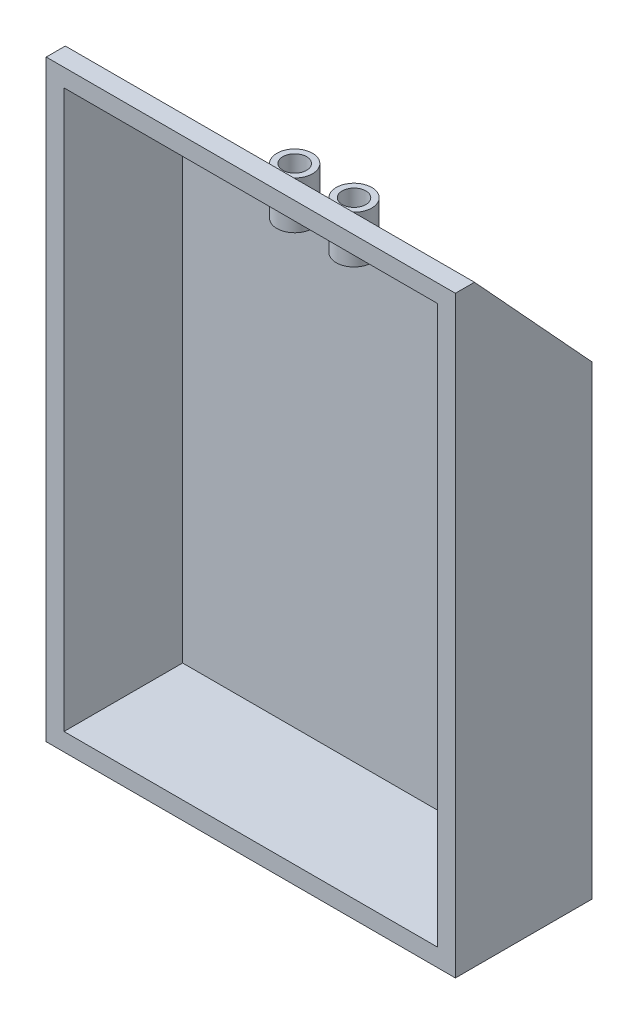
from build123d import *

# Parameters (mm, degrees)
IZIM1_W                     = 69
IZIM1_H                     = 100
Y_KSEKLIK_EKSTR_ZYON1_DEPTH = 3
IZIM2_W                     = 69
IZIM2_H                     = 100
IZIM2_W_2                   = 63
IZIM2_H_2                   = 94
Y_KSEKLIK_EKSTR_ZYON2_DEPTH = 20
KES_EKSTR_ZYON1_DEPTH       = 70
Y_KSEKLIK_EKSTR_ZYON3_DEPTH = 69
IZIM5_R                     = 3
KES_EKSTR_ZYON2_DEPTH       = 20
Y_KSEKLIK_EKSTR_ZYON4_START = -15
IZIM6_R                     = 3
IZIM6_R_2                   = 2
Y_KSEKLIK_EKSTR_ZYON4_DEPTH = 8


with BuildPart() as part:
    # Çizim1 → Yükseklik-Ekstrüzyon1 (new body)
    with BuildSketch(Plane.XY):
        Rectangle(IZIM1_W, IZIM1_H)
    extrude(amount=Y_KSEKLIK_EKSTR_ZYON1_DEPTH)

    # Çizim2 → Yükseklik-Ekstrüzyon2 (add)
    with BuildSketch(Plane.XY.offset(3)):
        Rectangle(IZIM2_W, IZIM2_H)
        Rectangle(IZIM2_W_2, IZIM2_H_2, mode=Mode.SUBTRACT)
    extrude(amount=Y_KSEKLIK_EKSTR_ZYON2_DEPTH)

    # Çizim3 → Kes-Ekstrüzyon1 (cut, through all)
    with BuildSketch(Plane(origin=(34.5, 0, 0), x_dir=(0, 0, -1), z_dir=(1, 0, 0))):
        Polygon((-23, 50), (0, 25), (0, 50), align=None)
    extrude(amount=-KES_EKSTR_ZYON1_DEPTH, mode=Mode.SUBTRACT)

    # Çizim4 → Yükseklik-Ekstrüzyon3 (add, through all)
    with BuildSketch(Plane(origin=(34.5, 0, 0), x_dir=(0, 0, -1), z_dir=(1, 0, 0))):
        Polygon((-23, 50), (-19.78, 50), (0, 28.5), (0, 25), align=None)
    extrude(amount=-Y_KSEKLIK_EKSTR_ZYON3_DEPTH)

    # Çizim5 → Kes-Ekstrüzyon2 (cut)
    with BuildSketch(Plane(origin=(0, 50, 0), x_dir=(1, 0, 0), z_dir=(0, 1, 0))):
        with Locations((-5, -10.594226135)):
            Circle(IZIM5_R)
        with Locations((5, -10.594226135)):
            Circle(IZIM5_R)
    extrude(amount=-KES_EKSTR_ZYON2_DEPTH, mode=Mode.SUBTRACT)

    # Çizim6 → Yükseklik-Ekstrüzyon4 (add)
    with BuildSketch(Plane(origin=(0, 50, 0), x_dir=(1, 0, 0), z_dir=(0, 1, 0)).offset(Y_KSEKLIK_EKSTR_ZYON4_START)):
        with Locations((-5, -10.594226135)):
            Circle(IZIM6_R)
        with Locations((-5, -10.594226135)):
            Circle(IZIM6_R_2, mode=Mode.SUBTRACT)
        with Locations((5, -10.594226135)):
            Circle(IZIM6_R)
        with Locations((5, -10.594226135)):
            Circle(IZIM6_R_2, mode=Mode.SUBTRACT)
    extrude(amount=Y_KSEKLIK_EKSTR_ZYON4_DEPTH)


solid = part.part
